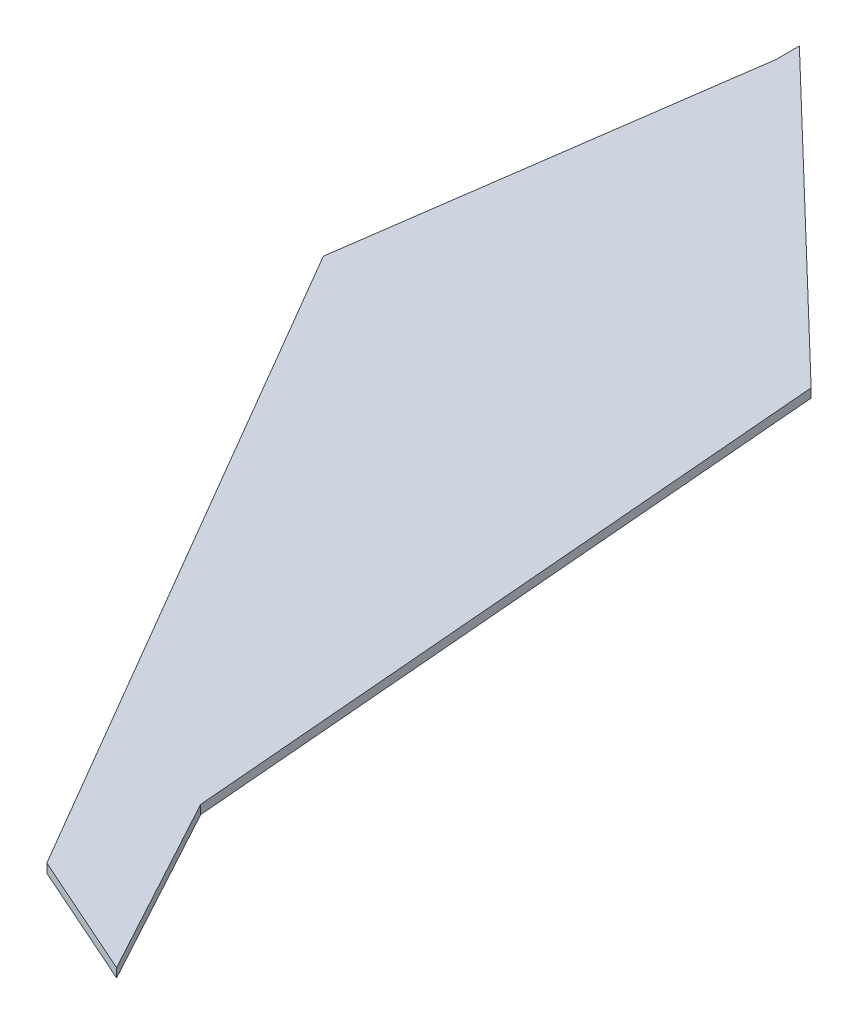
from build123d import *

# Parameters (mm, degrees)
BOSS_EXTRU_1_DEPTH = 2


with BuildPart() as part:
    # Esquisse1 → Boss.-Extru.1 (new body)
    with BuildSketch(Plane(origin=(0, 0, 0), x_dir=(1, 0, 0), z_dir=(0, 1, 0))):
        Polygon((-6.585404622, 178.142206662), (-74.356547449, 243.274741595), (-74.356547449, 237.978779523), (-86.923851243, 148.989480482), (0, 0), (28.191470123, -12.546520617), (5.877134787, 28.644503046), align=None)
    extrude(amount=BOSS_EXTRU_1_DEPTH)


solid = part.part
